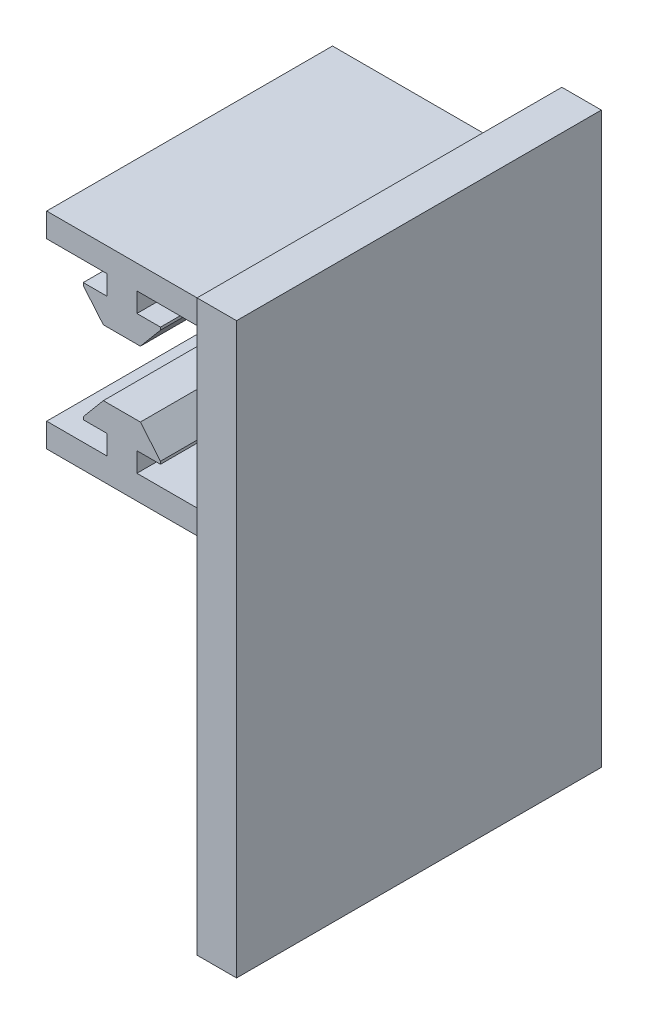
from build123d import *

# Parameters (mm, degrees)
BOSS_EXTRUDE1_DEPTH = 457.2
SKETCH2_W           = 42.050956734
SKETCH2_H           = 23.599286926
CUT_EXTRUDE1_DEPTH  = 800
SKETCH3_W           = 114.4
SKETCH3_H           = 56.436670765
BOSS_EXTRUDE2_DEPTH = 10
SKETCH4_W           = 114.4
SKETCH4_H           = 4.244670765
CUT_EXTRUDE2_DEPTH  = 10
SKETCH7_W           = 48.1
SKETCH7_H           = 52.192
CUT_EXTRUDE3_DEPTH  = 42
SKETCH8_W           = 0.9
SKETCH8_H           = 40
CUT_EXTRUDE4_DEPTH  = 90
BOSS_EXTRUDE3_DEPTH = 10


with BuildPart() as part:
    # Sketch1 → Boss-Extrude1 (new body, symmetric)
    with BuildSketch(Plane.XY):
        Polygon((-19.05, 8.89), (19.05, 8.89), (19.05, 2.794), (3.81, 2.794), (3.81, -2.159), (9.779, -2.159), (9.779, -2.8321), (4.695818344, -8.89), (-4.695818344, -8.89), (-9.779, -2.8321), (-9.779, -2.159), (-3.81, -2.159), (-3.81, 2.794), (-19.05, 2.794), align=None)
    boss_extrude1 = extrude(amount=BOSS_EXTRUDE1_DEPTH, both=True)

    # Sketch2 → Cut-Extrude1 (cut)
    with BuildSketch(Plane(origin=(0, 0, -457.2), x_dir=(-1, 0, 0), z_dir=(0, 0, -1))):
        Rectangle(SKETCH2_W, SKETCH2_H)
    cut_extrude1 = extrude(amount=-CUT_EXTRUDE1_DEPTH, mode=Mode.SUBTRACT)

    # Sketch3 → Boss-Extrude2 (add)
    with BuildSketch(Plane(origin=(19.05, 0, 0), x_dir=(0, 0, -1), z_dir=(1, 0, 0))):
        with Locations((-400, -19.328335383)):
            Rectangle(SKETCH3_W, SKETCH3_H)
    extrude(amount=BOSS_EXTRUDE2_DEPTH)

    # Mirror1: Boss-Extrude1, Cut-Extrude1 across plane
    add(boss_extrude1.mirror(Plane(origin=(0, -17.206, 0), x_dir=(0, 0, 1), z_dir=(0, -1, 0))))
    add(cut_extrude1.mirror(Plane(origin=(0, -17.206, 0), x_dir=(0, 0, 1), z_dir=(0, -1, 0))), mode=Mode.SUBTRACT)

    # Sketch4 → Cut-Extrude2 (cut)
    with BuildSketch(Plane.ZY.offset(-19.05)):
        with Locations((400, -45.424335383)):
            Rectangle(SKETCH4_W, SKETCH4_H)
    extrude(amount=-CUT_EXTRUDE2_DEPTH, mode=Mode.SUBTRACT)

    # Sketch7 → Cut-Extrude3 (cut)
    with BuildSketch(Plane.XY.offset(457.2)):
        with Locations((5, -17.206)):
            Rectangle(SKETCH7_W, SKETCH7_H)
    extrude(amount=-CUT_EXTRUDE3_DEPTH, mode=Mode.SUBTRACT)

    # Sketch8 → Cut-Extrude4 (cut)
    with BuildSketch(Plane(origin=(0, 0, 342.8), x_dir=(-1, 0, 0), z_dir=(0, 0, -1))):
        with Locations((-19.5, -17.206)):
            Rectangle(SKETCH8_W, SKETCH8_H)
    extrude(amount=-CUT_EXTRUDE4_DEPTH, mode=Mode.SUBTRACT)

    # Sketch10 → Boss-Extrude3 (add)
    with BuildSketch(Plane(origin=(29.05, 0, 0), x_dir=(0, 0, -1), z_dir=(1, 0, 0))):
        Polygon((-425.2, 18.89), (-332.8, 18.89), (-332.8, -53.302), (-332.8, -125.302), (-425.2, -125.302), (-425.2, -53.302), align=None)
    extrude(amount=BOSS_EXTRUDE3_DEPTH)


solid = part.part
